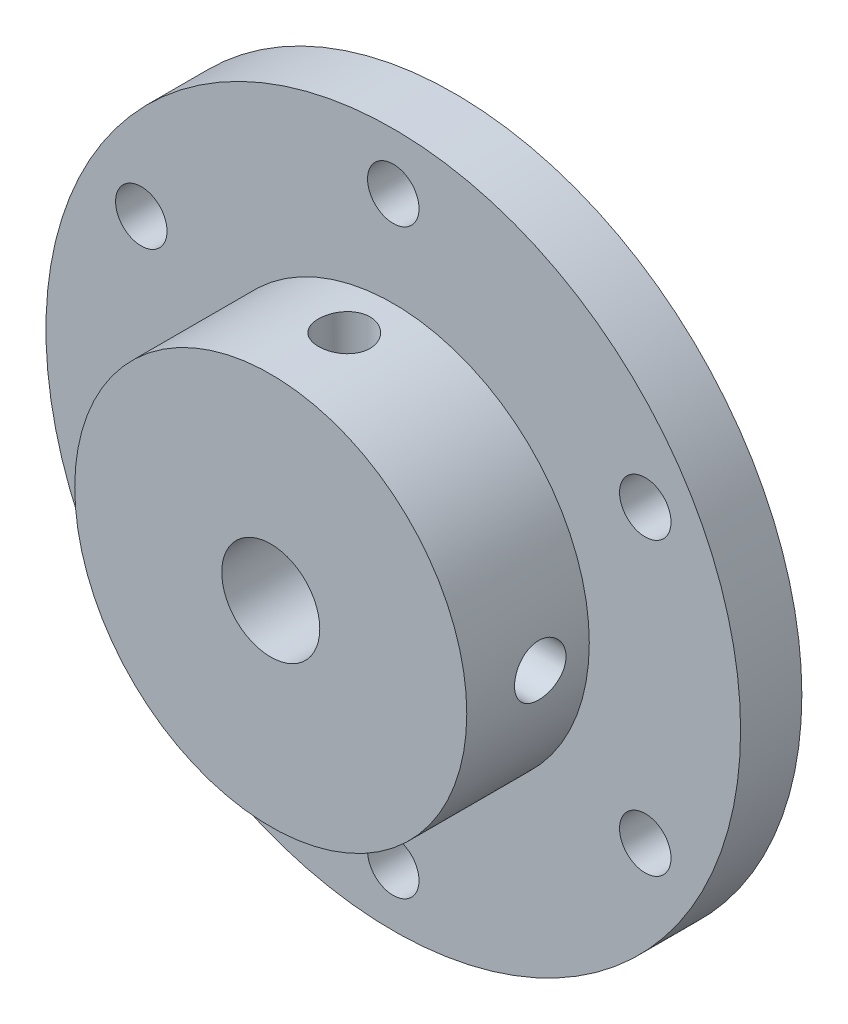
from build123d import *

# Parameters (mm, degrees)
SKETCH_1_R               = 28.35
EXTRUDE_1_DEPTH          = 5
SKETCH_2_R               = 16
EXTRUDE_2_DEPTH          = 10
SKETCH_3_R               = 4
CUT_EXTRUDE_1_DEPTH      = 16
M5X0_8_1_D               = 4.2
PATTERN_CIRCULAR_1_COUNT = 6
SKETCH_11_W              = 2.1
SKETCH_11_H              = 16.001
PATTERN_CIRCULAR_2_COUNT = 2
PATTERN_CIRCULAR_2_ANGLE = 90


with BuildPart() as part:
    # 草圖1 → 填料-伸長1 (new body)
    with BuildSketch(Plane.XY):
        Circle(SKETCH_1_R)
    extrude(amount=EXTRUDE_1_DEPTH)

    # 草圖2 → 填料-伸長2 (add)
    with BuildSketch(Plane.XY.offset(5)):
        Circle(SKETCH_2_R)
    extrude(amount=EXTRUDE_2_DEPTH)

    # 草圖3 → 除料-伸長1 (cut, through all)
    with BuildSketch(Plane.XY.offset(15)):
        Circle(SKETCH_3_R)
    extrude(amount=-CUT_EXTRUDE_1_DEPTH, mode=Mode.SUBTRACT)

    # M5x0.8 螺紋孔1 (through all)
    with Locations(Plane(origin=(0, 23.75, 5), x_dir=(1, 0, 0), z_dir=(0, 0, 1))):
        with Locations((0, 0)):
            m5x0_8_1 = Hole(M5X0_8_1_D / 2)

    # 環狀複製排列1: M5x0.8 螺紋孔1 ×6 about axis
    pattern_circular_1_axis = Axis((0, 0, 0), (0, 0, 1))
    for i in range(1, PATTERN_CIRCULAR_1_COUNT):
        add(m5x0_8_1.rotate(pattern_circular_1_axis, i * 360 / PATTERN_CIRCULAR_1_COUNT), mode=Mode.SUBTRACT)

    # 草圖11 → M5x0.8 螺紋孔2 (revolve, cut)
    with BuildSketch(Plane(origin=(0, 0, 9), x_dir=(0, 0, 1), z_dir=(0, 1, 0))):
        with Locations((1.05, 8.0005)):
            Rectangle(SKETCH_11_W, SKETCH_11_H)
    m5x0_8_2 = revolve(axis=Axis((-6.35, 0, 9), (1, 0, 0)), mode=Mode.SUBTRACT)

    # 環狀複製排列2: M5x0.8 螺紋孔2 ×2 about axis
    pattern_circular_2_axis = Axis((0, 0, 15), (0, 0, 1))
    for i in range(1, PATTERN_CIRCULAR_2_COUNT):
        add(m5x0_8_2.rotate(pattern_circular_2_axis, i * PATTERN_CIRCULAR_2_ANGLE / (PATTERN_CIRCULAR_2_COUNT - 1)), mode=Mode.SUBTRACT)


solid = part.part
